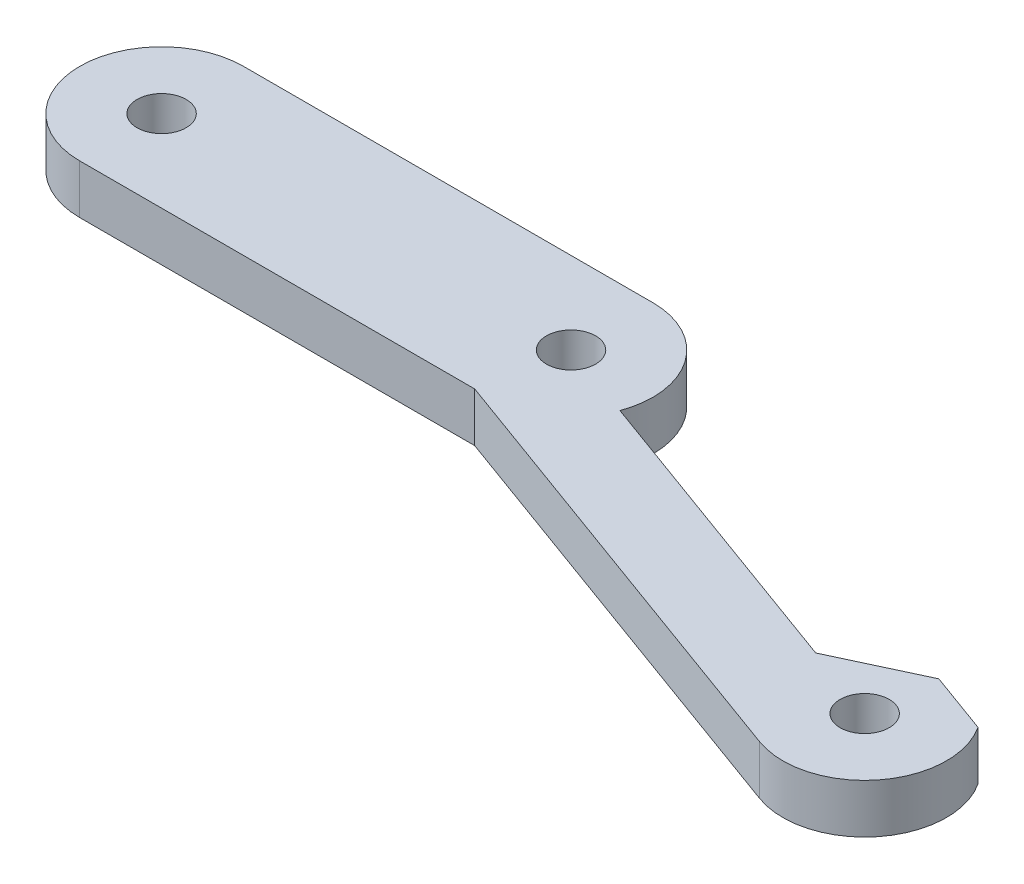
from build123d import *

# Parameters (mm, degrees)
SKETCH1_R           = 1.5
BOSS_EXTRUDE1_DEPTH = 3
CUT_EXTRUDE1_DEPTH  = 10


with BuildPart() as part:
    # Sketch1 → Boss-Extrude1 (new body)
    with BuildSketch(Plane(origin=(0, 0, 0), x_dir=(1, 0, 0), z_dir=(0, 1, 0))):
        with BuildLine():
            Line((25, 5), (0, 5))
            ThreePointArc((0, 5), (-5, 0), (0, -5))
            Line((0, -5), (24.118365096, -5))
            Line((24.118365096, -5), (51.480677907, -14.959067404))
            ThreePointArc((51.480677907, -14.959067404), (57.889241728, -11.970705016), (54.90087934, -5.562141196))
            Line((54.90087934, -5.562141196), (26.710100717, 4.698463104))
            ThreePointArc((26.710100717, 4.698463104), (25.868240888, 4.924038765), (25, 5))
        make_face()
        Circle(SKETCH1_R, mode=Mode.SUBTRACT)
        with Locations((25, 0)):
            Circle(SKETCH1_R, mode=Mode.SUBTRACT)
        with Locations((53.190778624, -10.2606043)):
            Circle(SKETCH1_R, mode=Mode.SUBTRACT)
    extrude(amount=BOSS_EXTRUDE1_DEPTH)

    # Sketch2 → Cut-Extrude1 (cut)
    with BuildSketch(Plane(origin=(0, 3, 0), x_dir=(1, 0, 0), z_dir=(0, 1, 0))):
        with BuildLine():
            Line((53.619166576, -6.159813673), (57.377937059, -7.527894247))
            ThreePointArc((57.377937059, -7.527894247), (56.298907102, -6.344032156), (54.90087934, -5.562141196))
            Line((54.90087934, -5.562141196), (26.710100717, 4.698463104))
            ThreePointArc((26.710100717, 4.698463104), (29.095760221, 2.867882182), (30, 0))
            ThreePointArc((30, 0), (29.924038765, -0.868240888), (29.698463104, -1.710100717))
            Line((29.698463104, -1.710100717), (48.49231552, -8.550503583))
            Line((48.49231552, -8.550503583), (53.619166576, -6.159813673))
        make_face()
    extrude(amount=-CUT_EXTRUDE1_DEPTH, mode=Mode.SUBTRACT)


solid = part.part
